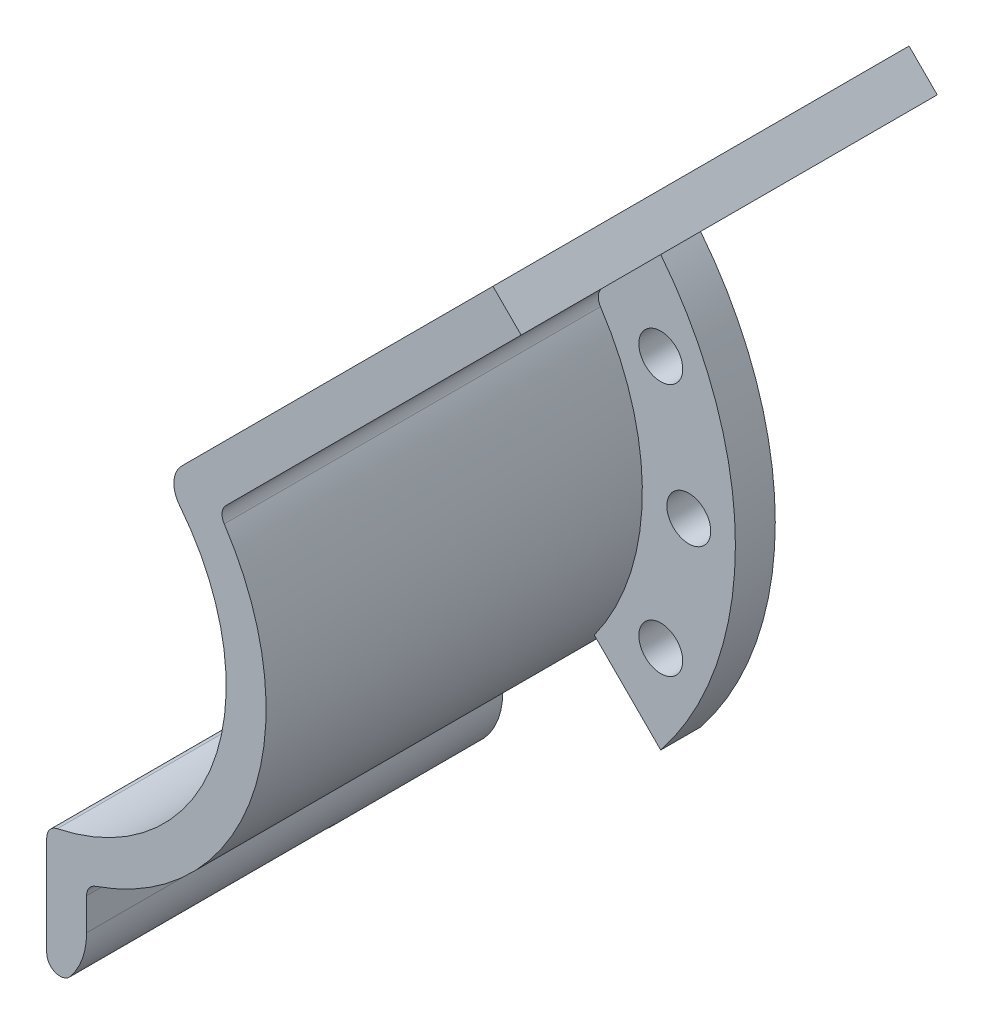
from build123d import *

# Parameters (mm, degrees)
EXTRUDE_1_DEPTH     = 31.3
EXTRUDE_2_DEPTH     = 3
EXTRUDE_3_DEPTH     = 31.3
SKETCH_9_W          = 7.730582044
SKETCH_9_H          = 5.996077833
CUT_EXTRUDE_1_DEPTH = 20
ST2_9_1_D           = 3.3
FILLET_1_R          = 1
FILLET_2_R          = 2


with BuildPart() as part:
    # 草图1 → 凸台-拉伸1 (new body)
    with BuildSketch(Plane.XY.offset(-1.3)):
        with BuildLine():
            Line((36.062445841, 36.062445841), (11.313708499, 11.313708499))
            ThreePointArc((11.313708499, 11.313708499), (15.216442494, -4.945692856), (2.5, -15.803480629))
            Line((2.5, -15.803480629), (2.5, -18.834808202))
            ThreePointArc((2.5, -18.834808202), (17.455469833, -7.50377058), (15.387819505, 11.145178818))
            Line((15.387819505, 11.145178818), (38.183766184, 33.941125497))
            Line((38.183766184, 33.941125497), (36.062445841, 36.062445841))
        make_face()
    extrude(amount=EXTRUDE_1_DEPTH)

    # 草图2 → 凸台-拉伸2 (add)
    with BuildSketch(Plane.XY.offset(-1.3)):
        with BuildLine():
            Line((15.387819505, 11.145178818), (20.383302711, 16.140662024))
            ThreePointArc((20.383302711, 16.140662024), (26, 0), (20.383302711, -16.140662024))
            Line((20.383302711, -16.140662024), (15.387819505, -11.145178818))
            ThreePointArc((15.387819505, -11.145178818), (19, 0), (15.387819505, 11.145178818))
        make_face()
    extrude(amount=EXTRUDE_2_DEPTH)

    # 草图8 → 凸台-拉伸3 (add)
    with BuildSketch(Plane.XY.offset(-1.3)):
        with BuildLine():
            Line((2.5, -18.834808202), (2.5, -21.334808202))
            ThreePointArc((2.5, -21.334808202), (1.767766953, -23.102575155), (0, -23.834808202))
            Line((0, -23.834808202), (0, -26.834808202))
            ThreePointArc((0, -26.834808202), (3.889087297, -25.223895498), (5.5, -21.334808202))
            Line((5.5, -21.334808202), (5.5, -18.186533479))
            ThreePointArc((5.5, -18.186533479), (4.013111639, -18.57134715), (2.5, -18.834808202))
        make_face()
    extrude(amount=EXTRUDE_3_DEPTH)

    # 草图9 → 切除-拉伸1 (cut)
    with BuildSketch(Plane.XY.offset(30)):
        with Locations((-1.365291022, -24.332847119)):
            Rectangle(SKETCH_9_W, SKETCH_9_H)
    extrude(amount=-CUT_EXTRUDE_1_DEPTH, mode=Mode.SUBTRACT)

    # ST2.9 间隙孔1 (through all)
    with Locations(Plane.XY.offset(1.7)):
        with Locations((22.494945516, 0), (20.38734429, 9.506774772), (20.38734429, -9.506774772)):
            Hole(ST2_9_1_D / 2)

    # 圆角1
    fillet_1_edges = [part.edges().sort_by_distance(p)[0] for p in [
        (2.5, -15.803480629, 14.35),
        (15.387819505, 11.145178818, 15.85),
        (5.5, -18.186533479, 14.35),
        (2.5, -26.233787687, 20),
    ]]
    fillet(fillet_1_edges, radius=FILLET_1_R)

    # 圆角2
    fillet_2_edges = [part.edges().sort_by_distance(p)[0] for p in [
        (11.313708499, 11.313708499, 14.35),
    ]]
    fillet(fillet_2_edges, radius=FILLET_2_R)


solid = part.part
